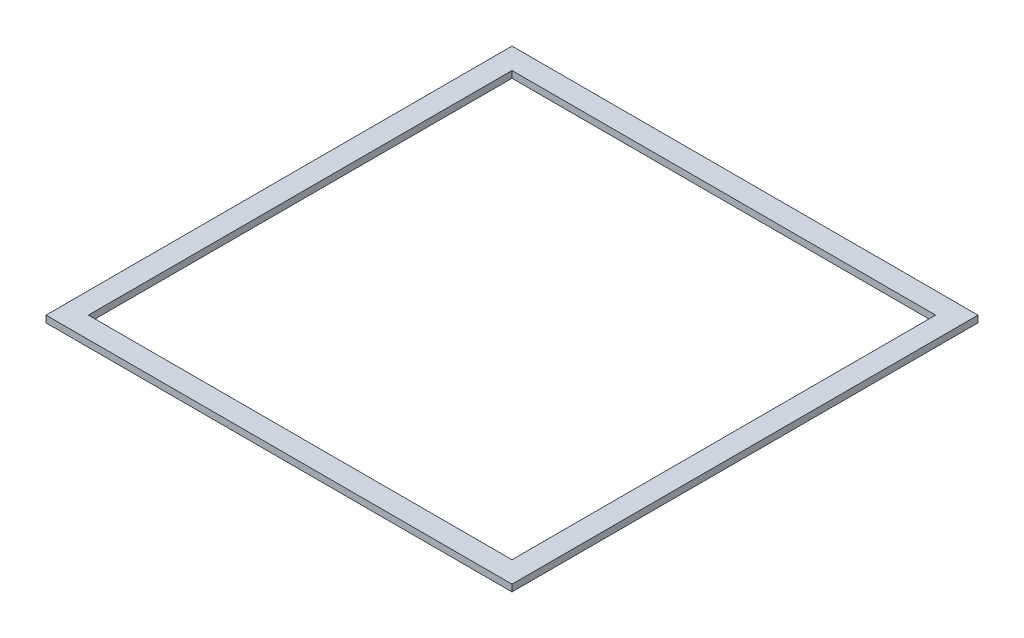
from build123d import *

# Parameters (mm, degrees)
SKETCH1_W           = 110
SKETCH1_H           = 110
SKETCH1_W_2         = 100
SKETCH1_H_2         = 100
BOSS_EXTRUDE1_DEPTH = 0.79375


with BuildPart() as part:
    # Sketch1 → Boss-Extrude1 (new body, symmetric)
    with BuildSketch(Plane(origin=(0, 0, 0), x_dir=(1, 0, 0), z_dir=(0, 1, 0))):
        Rectangle(SKETCH1_W, SKETCH1_H)
        Rectangle(SKETCH1_W_2, SKETCH1_H_2, mode=Mode.SUBTRACT)
    extrude(amount=BOSS_EXTRUDE1_DEPTH, both=True)


solid = part.part
